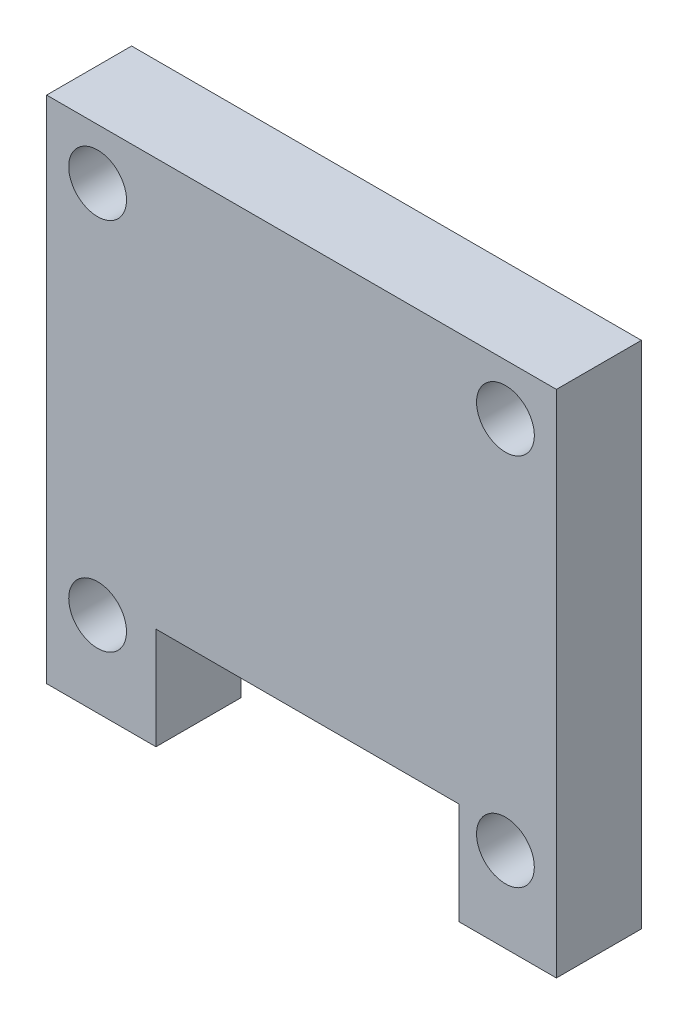
from build123d import *

# Parameters (mm, degrees)
SKETCH1_W           = 30
SKETCH1_H           = 30
SKETCH1_R           = 1.7
BOSS_EXTRUDE1_DEPTH = 5
SKETCH3_W           = 17.830647844
SKETCH3_H           = 6
CUT_EXTRUDE1_DEPTH  = 5


with BuildPart() as part:
    # Sketch1 → Boss-Extrude1 (new body)
    with BuildSketch(Plane.XY):
        with Locations((15, 15)):
            Rectangle(SKETCH1_W, SKETCH1_H)
        with Locations((3, 27)):
            Circle(SKETCH1_R, mode=Mode.SUBTRACT)
        with Locations((27, 27)):
            Circle(SKETCH1_R, mode=Mode.SUBTRACT)
        with Locations((27, 5)):
            Circle(SKETCH1_R, mode=Mode.SUBTRACT)
        with Locations((3, 5)):
            Circle(SKETCH1_R, mode=Mode.SUBTRACT)
    extrude(amount=BOSS_EXTRUDE1_DEPTH)

    # Sketch3 → Cut-Extrude1 (cut)
    with BuildSketch(Plane.XY.offset(5)):
        with Locations((15.350024265, 3)):
            Rectangle(SKETCH3_W, SKETCH3_H)
    extrude(amount=-CUT_EXTRUDE1_DEPTH, mode=Mode.SUBTRACT)


solid = part.part
